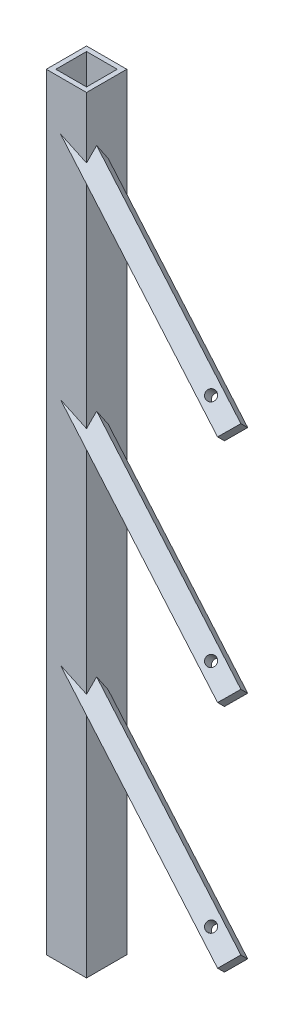
from build123d import *

# Parameters (mm, degrees)
SKETCH2_W                = 21
SKETCH2_H                = 21
BOSS_EXTRUDE1_DEPTH      = 300
BOSS_EXTRUDE1_DEPTH_BACK = 100
SKETCH3_W                = 16
SKETCH3_H                = 16
CUT_EXTRUDE1_DEPTH       = 800
SKETCH14_R               = 2.5
BOSS_EXTRUDE3_DEPTH      = 10
LPATTERN1_COUNT          = 3
LPATTERN1_PITCH          = 120


with BuildPart() as part:
    # Sketch2 → Boss-Extrude1 (new body, two sides)
    with BuildSketch(Plane(origin=(0, 0, 0), x_dir=(1, 0, 0), z_dir=(0, 1, 0))) as boss_extrude1_sk:
        Rectangle(SKETCH2_W, SKETCH2_H)
    extrude(amount=BOSS_EXTRUDE1_DEPTH)
    extrude(boss_extrude1_sk.sketch, amount=-BOSS_EXTRUDE1_DEPTH_BACK)

    # Sketch3 → Cut-Extrude1 (cut)
    with BuildSketch(Plane.XZ.offset(100)):
        Rectangle(SKETCH3_W, SKETCH3_H)
    extrude(amount=-CUT_EXTRUDE1_DEPTH, mode=Mode.SUBTRACT)

    # Sketch14 → Boss-Extrude3 (add)
    with BuildSketch(Plane(origin=(9.15884387, 19.641204062, 19.641204062), x_dir=(0.949705125, -0.221427386, -0.221427386), z_dir=(0.313145613, 0.671542934, 0.671542934))):
        Polygon((-12.902384486, 16.967939861), (98.008310235, -50.846644091), (103.224816692, -42.31505219), (-7.685878028, 25.499531762), align=None)
        with Locations((87.819175611, -38.756088454)):
            Circle(SKETCH14_R, mode=Mode.SUBTRACT)
    boss_extrude3 = extrude(amount=-BOSS_EXTRUDE3_DEPTH)

    # LPattern1: Boss-Extrude3 ×3
    with Locations(*[(0, i * LPATTERN1_PITCH, 0) for i in range(1, LPATTERN1_COUNT)]):
        add(boss_extrude3)


solid = part.part
